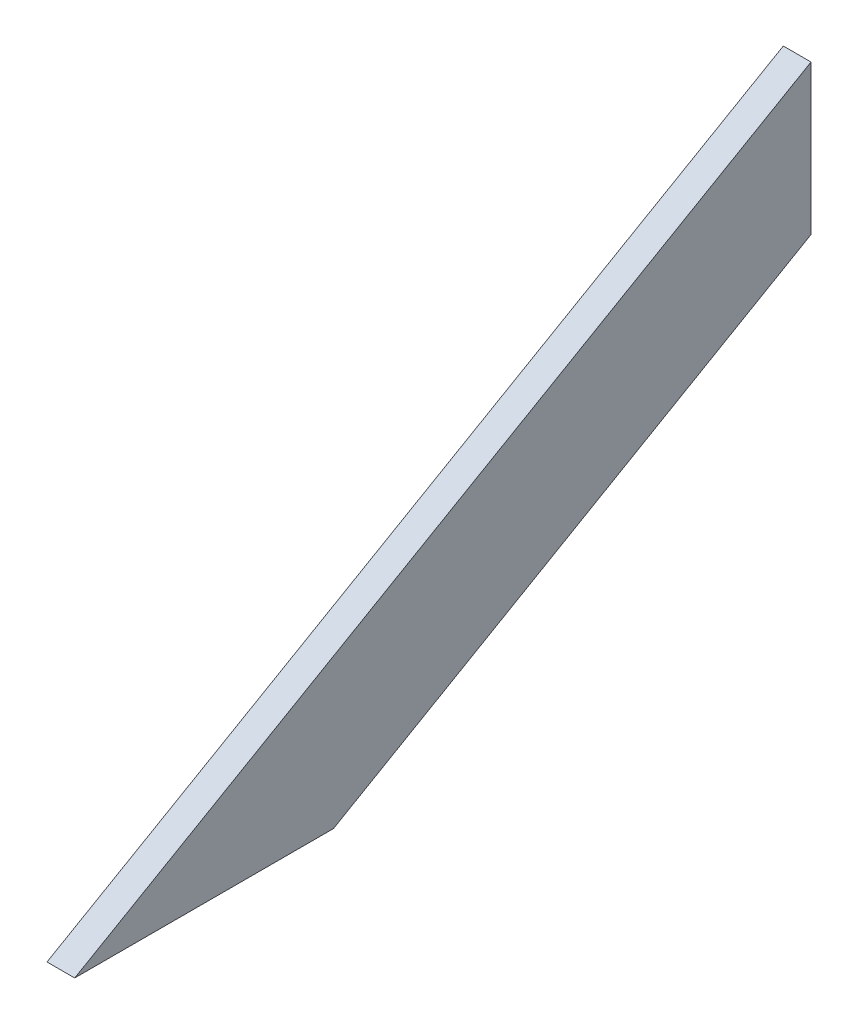
from build123d import *

# Parameters (mm, degrees)
BOSS_EXTRUDE1_DEPTH = 19.05


with BuildPart() as part:
    # Sketch1 → Boss-Extrude1 (new body)
    with BuildSketch(Plane(origin=(0, 0, 0), x_dir=(0, 0, -1), z_dir=(1, 0, 0))):
        Polygon((0, 0), (177.8, 0), (505.932040891, 189.447122138), (505.932040891, 292.1), align=None)
    extrude(amount=BOSS_EXTRUDE1_DEPTH)


solid = part.part
